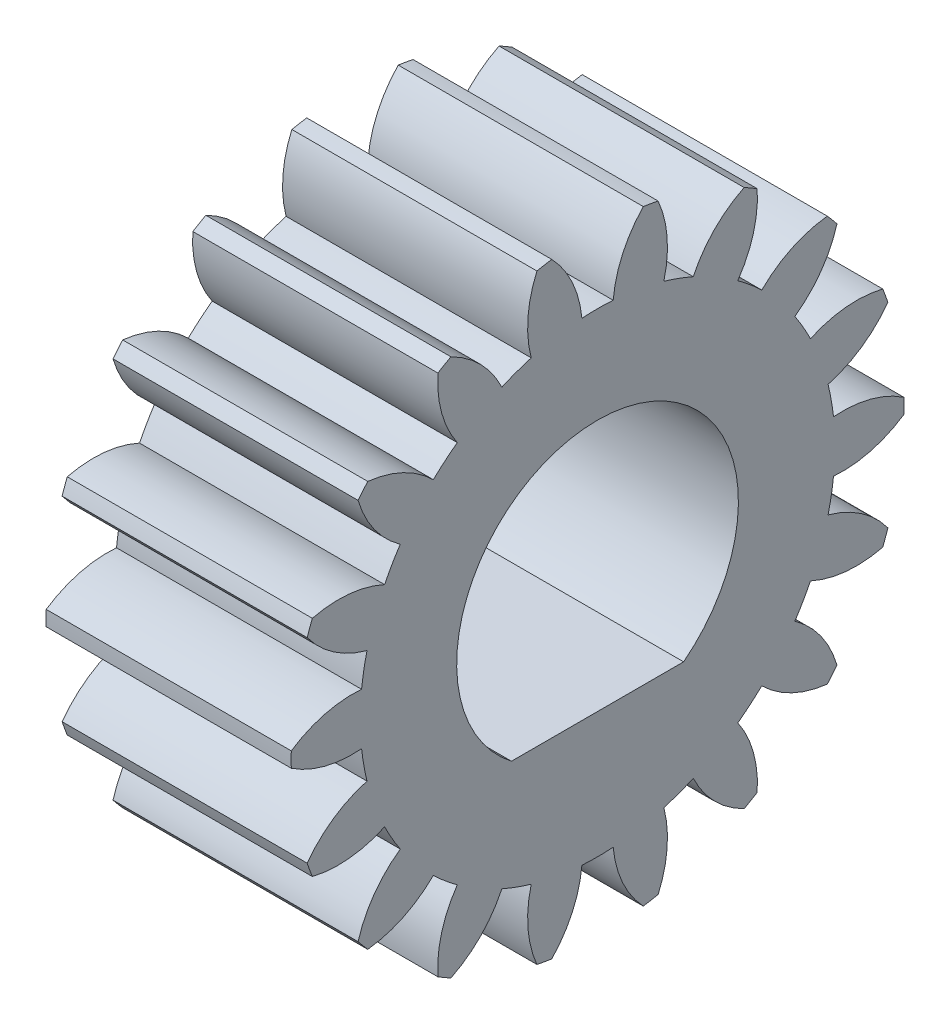
from build123d import *

# Parameters (mm, degrees)
BASPROSKE_W     = 4
BASPROSKE_H     = 5
TOOTHCUT_DEPTH  = 9.124038405
TEETHCUTS_COUNT = 18
TEETHCUTS_ANGLE = 340
BORE_DEPTH      = 50.0000508


with BuildPart() as part:
    # BasProSke → Base-Revolve (revolve)
    with BuildSketch(Plane(origin=(0, 0, 0), x_dir=(1, 0, 0), z_dir=(0, 1, 0)), mode=Mode.PRIVATE) as base_revolve_sk:
        with Locations((2, 2.5)):
            Rectangle(BASPROSKE_W, BASPROSKE_H)
    revolve(base_revolve_sk.sketch.rotate(Axis((-10, 0, 0), (1, 0, 0)), 180), axis=Axis((-10, 0, 0), (1, 0, 0)))

    # TooCutSke → ToothCut (cut, through all)
    with BuildSketch(Plane(origin=(0, 0, 0), x_dir=(0, 0, -1), z_dir=(1, 0, 0))):
        with BuildLine():
            ThreePointArc((0.25527463, 3.865580275), (0, 3.874), (-0.25527463, 3.865580275))
            ThreePointArc((-0.25527463, 3.865580275), (-0.416281865, 4.46052923), (-0.768562654, 4.96628197))
            ThreePointArc((-0.768562654, 4.96628197), (0, 5.0254), (0.768562654, 4.96628197))
            ThreePointArc((0.768562654, 4.96628197), (0.416281865, 4.46052923), (0.25527463, 3.865580275))
        make_face()
    toothcut = extrude(amount=TOOTHCUT_DEPTH, mode=Mode.SUBTRACT)

    # TeethCuts: ToothCut ×18 about axis
    teethcuts_axis = Axis((-10, 0, 0), (1, 0, 0))
    for i in range(1, TEETHCUTS_COUNT):
        add(toothcut.rotate(teethcuts_axis, i * TEETHCUTS_ANGLE / (TEETHCUTS_COUNT - 1)), mode=Mode.SUBTRACT)

    # BorSke → Bore (cut, symmetric)
    with BuildSketch(Plane(origin=(0, 0, 0), x_dir=(0, 0, -1), z_dir=(1, 0, 0))):
        with BuildLine():
            Line((-1.40479833, -1.82), (1.40479833, -1.82))
            ThreePointArc((1.40479833, -1.82), (0, 2.299099464), (-1.40479833, -1.82))
        make_face()
    extrude(amount=BORE_DEPTH, both=True, mode=Mode.SUBTRACT)


solid = part.part
